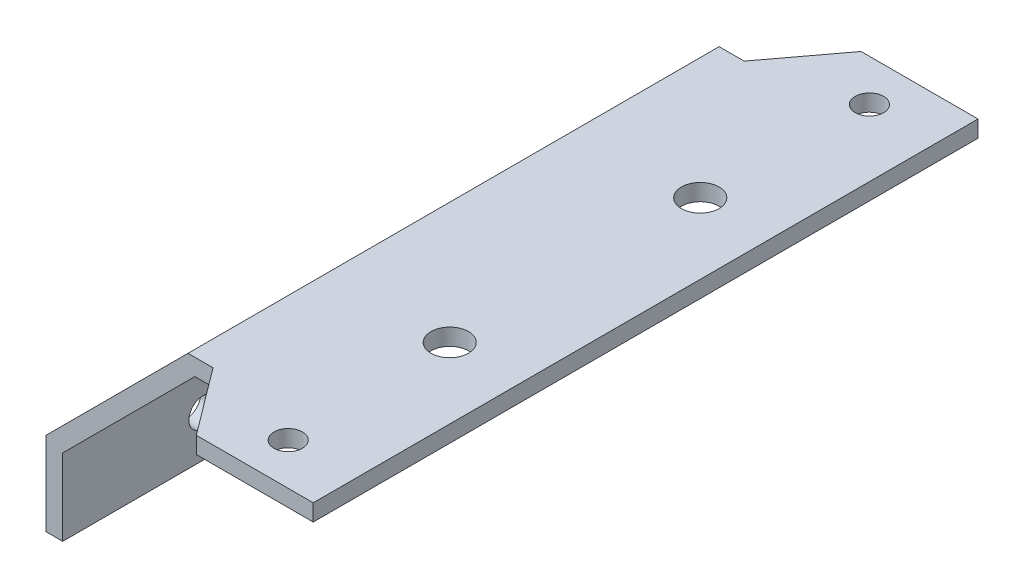
from build123d import *

# Parameters (mm, degrees)
BOSS_EXTRUDE1_DEPTH      = 31.8
M3_CLEARANCE_HOLE1_D     = 3.4
M3_CLEARANCE_HOLE1_DEPTH = 5
M3_CLEARANCE_HOLE1_TIP   = 1.021463052
BOSS_EXTRUDE2_DEPTH      = 2
M3_CLEARANCE_HOLE2_D     = 3.4
M3_CLEARANCE_HOLE2_DEPTH = 5
M3_CLEARANCE_HOLE2_TIP   = 1.021463052
M4_CLEARANCE_HOLE1_D     = 4.5


with BuildPart() as part:
    # Sketch1 → Boss-Extrude1 (new body, symmetric)
    with BuildSketch(Plane.XY):
        Polygon((0, 0), (0, 9.171572875), (15.828427125, 25), (38, 25), (38, 27), (15, 27), (-2, 10), (-2, 0), align=None)
    extrude(amount=BOSS_EXTRUDE1_DEPTH, both=True)

    # M3 Clearance Hole1
    with Locations(Plane(origin=(0, 0, 0), x_dir=(0, 0, -1), z_dir=(1, 0, 0))):
        with Locations((5, 5), (-5, 5), (-15, 5), (15, 5)):
            Hole(M3_CLEARANCE_HOLE1_D / 2, depth=M3_CLEARANCE_HOLE1_DEPTH)
            with Locations((0, 0, -(M3_CLEARANCE_HOLE1_DEPTH + M3_CLEARANCE_HOLE1_TIP / 2))):  # 118° drill point
                Cone(0, M3_CLEARANCE_HOLE1_D / 2, M3_CLEARANCE_HOLE1_TIP, mode=Mode.SUBTRACT)

    # Sketch4 → Boss-Extrude2 (add)
    with BuildSketch(Plane(origin=(0, 27, 0), x_dir=(1, 0, 0), z_dir=(0, 1, 0))):
        Polygon((18, -31.8), (24, -39.8), (38, -39.8), (38, -31.8), align=None)
    boss_extrude2 = extrude(amount=-BOSS_EXTRUDE2_DEPTH)

    # Mirror1: Boss-Extrude2 across plane
    add(boss_extrude2.mirror(Plane.XY))

    # M3 Clearance Hole2
    with Locations(Plane(origin=(0, 27, 0), x_dir=(1, 0, 0), z_dir=(0, 1, 0))):
        with Locations((30, 34.8), (30, -34.8)):
            Hole(M3_CLEARANCE_HOLE2_D / 2, depth=M3_CLEARANCE_HOLE2_DEPTH)
            with Locations((0, 0, -(M3_CLEARANCE_HOLE2_DEPTH + M3_CLEARANCE_HOLE2_TIP / 2))):  # 118° drill point
                Cone(0, M3_CLEARANCE_HOLE2_D / 2, M3_CLEARANCE_HOLE2_TIP, mode=Mode.SUBTRACT)

    # M4 Clearance Hole1 (through all)
    with Locations(Plane(origin=(0, 25, 0), x_dir=(-1, 0, 0), z_dir=(0, -1, 0))):
        with Locations((-29.541515225, 15), (-29.541515225, -15)):
            Hole(M4_CLEARANCE_HOLE1_D / 2)


solid = part.part
